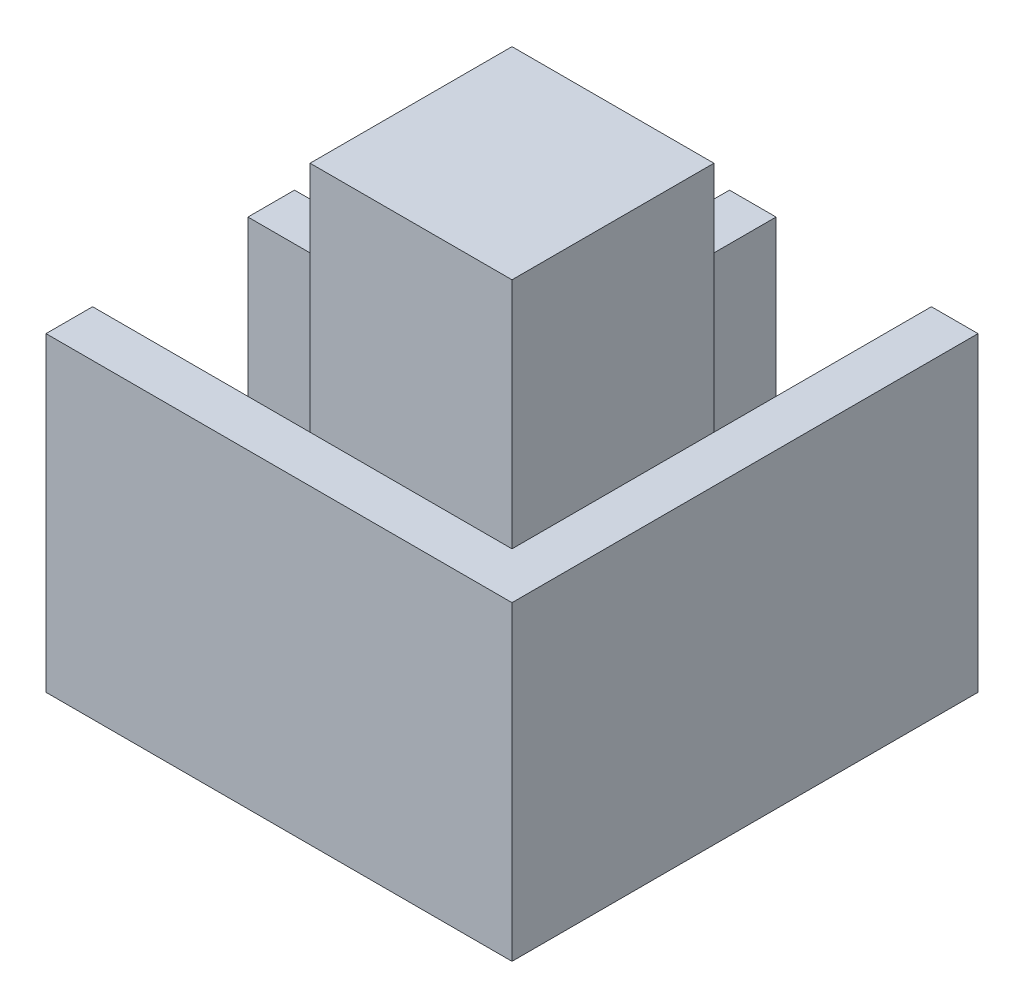
from build123d import *

# Parameters (mm, degrees)
SKETCH1_W           = 30
SKETCH1_H           = 30
BOSS_EXTRUDE1_DEPTH = 20
SKETCH1_6_W         = 10
SKETCH1_6_H         = 14
SKETCH1_6_W_2       = 14
SKETCH1_6_H_2       = 10
CUT_EXTRUDE1_DEPTH  = 15
SKETCH1_7_W         = 13
SKETCH1_7_H         = 13
BOSS_EXTRUDE2_DEPTH = 15


with BuildPart() as part:
    # Sketch1 → Boss-Extrude1 (new body)
    with BuildSketch(Plane(origin=(0, 0, 0), x_dir=(1, 0, 0), z_dir=(0, 1, 0))):
        Rectangle(SKETCH1_W, SKETCH1_H)
    extrude(amount=-BOSS_EXTRUDE1_DEPTH)

    # Sketch1_6 → Cut-Extrude1 (cut)
    with BuildSketch(Plane(origin=(0, 0, 0), x_dir=(1, 0, 0), z_dir=(0, 1, 0))):
        with Locations((7, 8)):
            Rectangle(SKETCH1_6_W, SKETCH1_6_H)
        with Locations((-8, -7)):
            Rectangle(SKETCH1_6_W_2, SKETCH1_6_H_2)
        with Locations((-8, 8)):
            Rectangle(SKETCH1_6_W_2, SKETCH1_6_H)
    extrude(amount=-CUT_EXTRUDE1_DEPTH, mode=Mode.SUBTRACT)

    # Sketch1_7 → Boss-Extrude2 (add)
    with BuildSketch(Plane(origin=(0, 0, 0), x_dir=(1, 0, 0), z_dir=(0, 1, 0))):
        with Locations((5.5, -5.5)):
            Rectangle(SKETCH1_7_W, SKETCH1_7_H)
    extrude(amount=BOSS_EXTRUDE2_DEPTH)


solid = part.part
